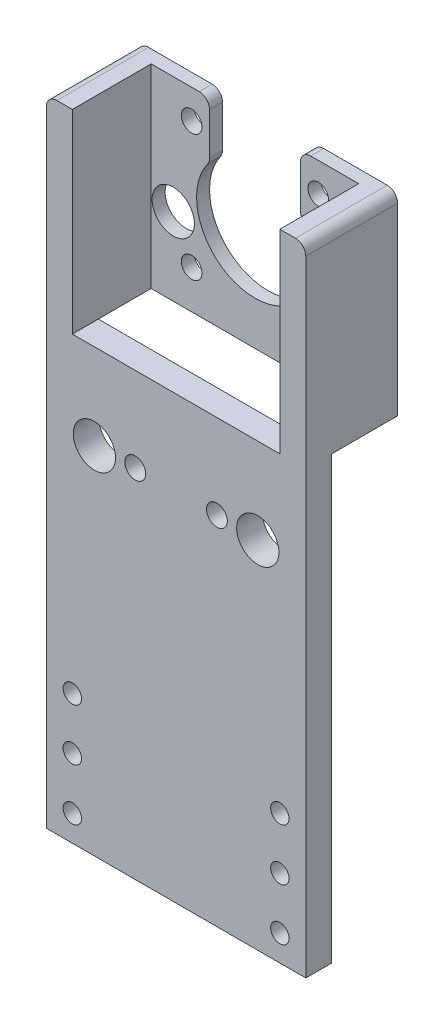
from build123d import *

# Parameters (mm, degrees)
SKETCH1_W           = 6.35
SKETCH1_H           = 107.95
BOSS_EXTRUDE1_DEPTH = 31.75
BOSS_EXTRUDE2_DEPTH = 19.304
SKETCH3_W           = 63.5
SKETCH3_H           = 47.625
BOSS_EXTRUDE3_DEPTH = 3.175
SKETCH5_R           = 2.54
CUT_EXTRUDE2_DEPTH  = 23.479
FILLET1_R           = 2.54
CUT_EXTRUDE4_START  = -6.35
SKETCH7_W           = 50.8
SKETCH7_H           = 19.304
CUT_EXTRUDE4_DEPTH  = 6.35
SKETCH9_R           = 2.25
CUT_EXTRUDE5_DEPTH  = 23.479
SKETCH15_R          = 2.55
SKETCH15_R_2        = 5.175
CUT_EXTRUDE8_DEPTH  = 23.479
LPATTERN1_COUNT     = 3
LPATTERN1_PITCH     = 12.7


with BuildPart() as part:
    # Sketch1 → Boss-Extrude1 (new body, symmetric)
    with BuildSketch(Plane(origin=(0, 0, 0), x_dir=(0, 0, -1), z_dir=(1, 0, 0))):
        with Locations((3.175, 0)):
            Rectangle(SKETCH1_W, SKETCH1_H)
    extrude(amount=BOSS_EXTRUDE1_DEPTH, both=True)

    # Sketch2 → Boss-Extrude2 (add)
    with BuildSketch(Plane.XY):
        Polygon((-31.75, 53.975), (-31.75, 101.6), (-25.4, 101.6), (25.4, 101.6), (31.75, 101.6), (31.75, 53.975), (25.4, 53.975), (25.4, 95.25), (-25.4, 95.25), (-25.4, 53.975), align=None)
    extrude(amount=-BOSS_EXTRUDE2_DEPTH)

    # Sketch3 → Boss-Extrude3 (add)
    with BuildSketch(Plane(origin=(0, 0, -19.304), x_dir=(-1, 0, 0), z_dir=(0, 0, -1))):
        with Locations((0, 77.7875)):
            Rectangle(SKETCH3_W, SKETCH3_H)
    extrude(amount=BOSS_EXTRUDE3_DEPTH)

    # Sketch5 → Cut-Extrude2 (cut, through all)
    with BuildSketch(Plane(origin=(0, 0, -22.479), x_dir=(-1, 0, 0), z_dir=(0, 0, -1))):
        with Locations((15.5, 94.425)):
            Circle(SKETCH5_R)
        with Locations((15.5, 63.425)):
            Circle(SKETCH5_R)
        with Locations((-15.5, 63.425)):
            Circle(SKETCH5_R)
        with Locations((-15.5, 94.425)):
            Circle(SKETCH5_R)
        with BuildLine():
            Line((-11.1125, 87.905256121), (-11.1125, 101.6))
            Line((-11.1125, 101.6), (11.1125, 101.6))
            Line((11.1125, 101.6), (11.1125, 87.905256121))
            ThreePointArc((11.1125, 87.905256121), (0, 64.6375), (-11.1125, 87.905256121))
        make_face()
    extrude(amount=-CUT_EXTRUDE2_DEPTH, mode=Mode.SUBTRACT)

    # Fillet1
    fillet1_edges = [part.edges().sort_by_distance(p)[0] for p in [
        (-31.75, 101.6, -11.2395),
        (31.75, 101.6, -11.2395),
        (-11.1125, 87.905256121, -20.8915),
        (11.1125, 87.905256121, -20.8915),
        (11.1125, 101.6, -11.2395),
        (-11.1125, 101.6, -11.2395),
    ]]
    fillet(fillet1_edges, radius=FILLET1_R)

    # Sketch7 → Cut-Extrude4 (cut)
    with BuildSketch(Plane(origin=(0, 101.6, 0), x_dir=(1, 0, 0), z_dir=(0, 1, 0)).offset(CUT_EXTRUDE4_START)):
        with Locations((0, 9.652)):
            Rectangle(SKETCH7_W, SKETCH7_H)
    extrude(amount=CUT_EXTRUDE4_DEPTH, mode=Mode.SUBTRACT)

    # Sketch9 → Cut-Extrude5 (cut, through all)
    with BuildSketch(Plane.XY):
        with Locations((25.4, -47.625)):
            Circle(SKETCH9_R)
        with Locations((-25.4, -47.625)):
            Circle(SKETCH9_R)
    cut_extrude5 = extrude(amount=-CUT_EXTRUDE5_DEPTH, mode=Mode.SUBTRACT)

    # Sketch15 → Cut-Extrude8 (cut, through all)
    with BuildSketch(Plane.XY):
        with Locations((10, 72.981043446)):
            Circle(SKETCH15_R)
        with Locations((-10, 33.281043446)):
            Circle(SKETCH15_R)
        with Locations((-10, 72.981043446)):
            Circle(SKETCH15_R)
        with Locations((10, 33.281043446)):
            Circle(SKETCH15_R)
        with Locations((-20, 72.981043446)):
            Circle(SKETCH15_R_2)
        with Locations((20, 72.981043446)):
            Circle(SKETCH15_R_2)
        with Locations((20, 32.981043446)):
            Circle(SKETCH15_R_2)
        with Locations((-20, 32.981043446)):
            Circle(SKETCH15_R_2)
    extrude(amount=-CUT_EXTRUDE8_DEPTH, mode=Mode.SUBTRACT)

    # LPattern1: Cut-Extrude5 ×3
    with Locations(*[(0, i * LPATTERN1_PITCH, 0) for i in range(1, LPATTERN1_COUNT)]):
        add(cut_extrude5, mode=Mode.SUBTRACT)


solid = part.part
